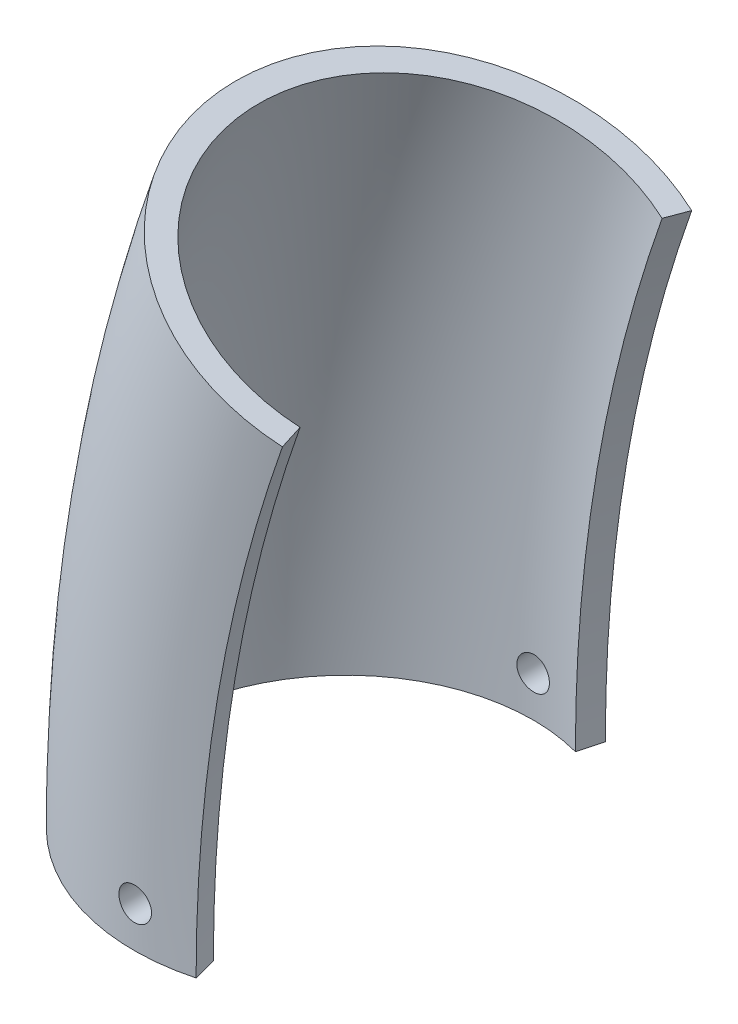
from build123d import *

# Parameters (mm, degrees)
SKETCH3_R               = 6.35
CUT_EXTRUDE1_DEPTH      = 83.5500001
CUT_EXTRUDE1_DEPTH_BACK = 83.5500001


with BuildPart() as part:
    # Sweep1: sweep along a path in Sketch1
    with BuildLine(Plane.XY) as sweep1_path:
        ThreePointArc((0, 0), (8.779118035, 103.084566231), (34.863608252, 203.2))
    # Sketch2 → Sweep1 (sweep)
    with BuildSketch(Plane(origin=(0, 0, 0), x_dir=(1, 0, 0), z_dir=(0, 1, 0))):
        with BuildLine():
            Line((18.900260769, -70.536733465), (21.365512173, -79.73717696))
            ThreePointArc((21.365512173, -79.73717696), (-82.55, 0), (21.365512173, 79.73717696))
            Line((21.365512173, 79.73717696), (18.900260769, 70.536733465))
            ThreePointArc((18.900260769, 70.536733465), (-73.025, 0), (18.900260769, -70.536733465))
        make_face()
    sweep(path=sweep1_path.line)

    # Sketch3 → Cut-Extrude1 (cut, two sides)
    with BuildSketch(Plane.XY) as cut_extrude1_sk:
        with Locations((0.206740786, 15.875)):
            Circle(SKETCH3_R)
    extrude(amount=CUT_EXTRUDE1_DEPTH, mode=Mode.SUBTRACT)
    extrude(cut_extrude1_sk.sketch, amount=-CUT_EXTRUDE1_DEPTH_BACK, mode=Mode.SUBTRACT)


solid = part.part
